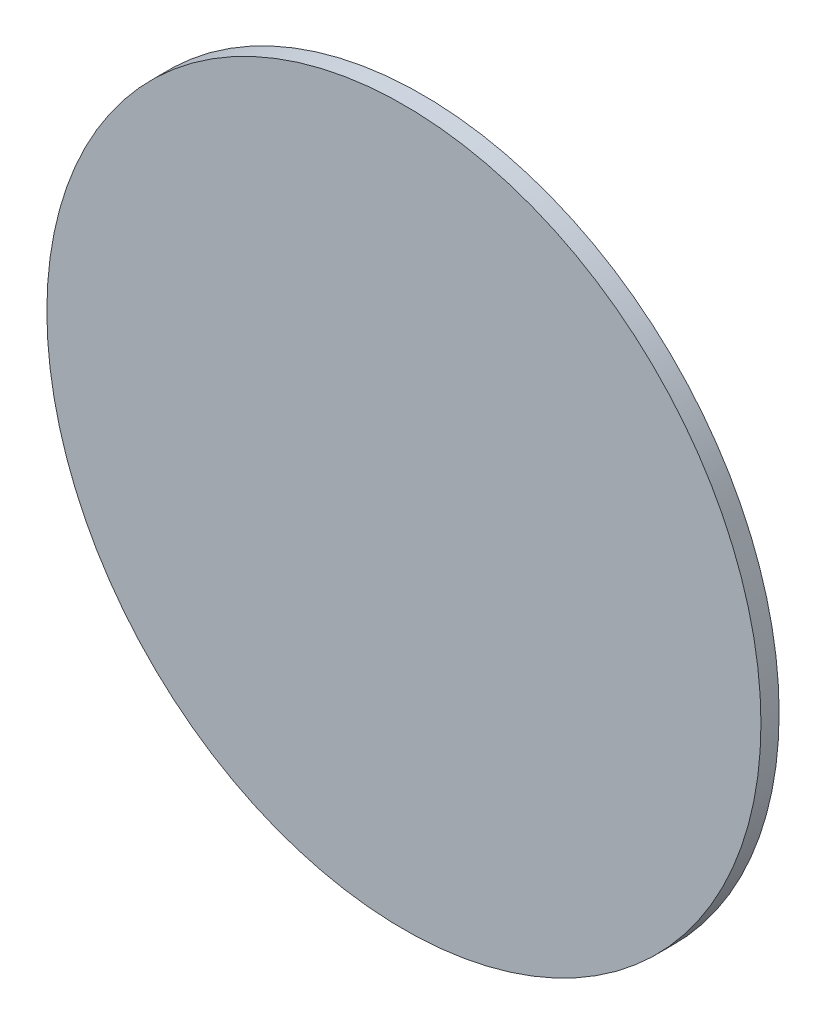
from build123d import *

# Parameters (mm, degrees)
SKETCH1_R           = 133.5
BOSS_EXTRUDE1_DEPTH = 6.8


with BuildPart() as part:
    # Sketch1 → Boss-Extrude1 (new body)
    with BuildSketch(Plane.XY):
        Circle(SKETCH1_R)
    extrude(amount=BOSS_EXTRUDE1_DEPTH)


solid = part.part
